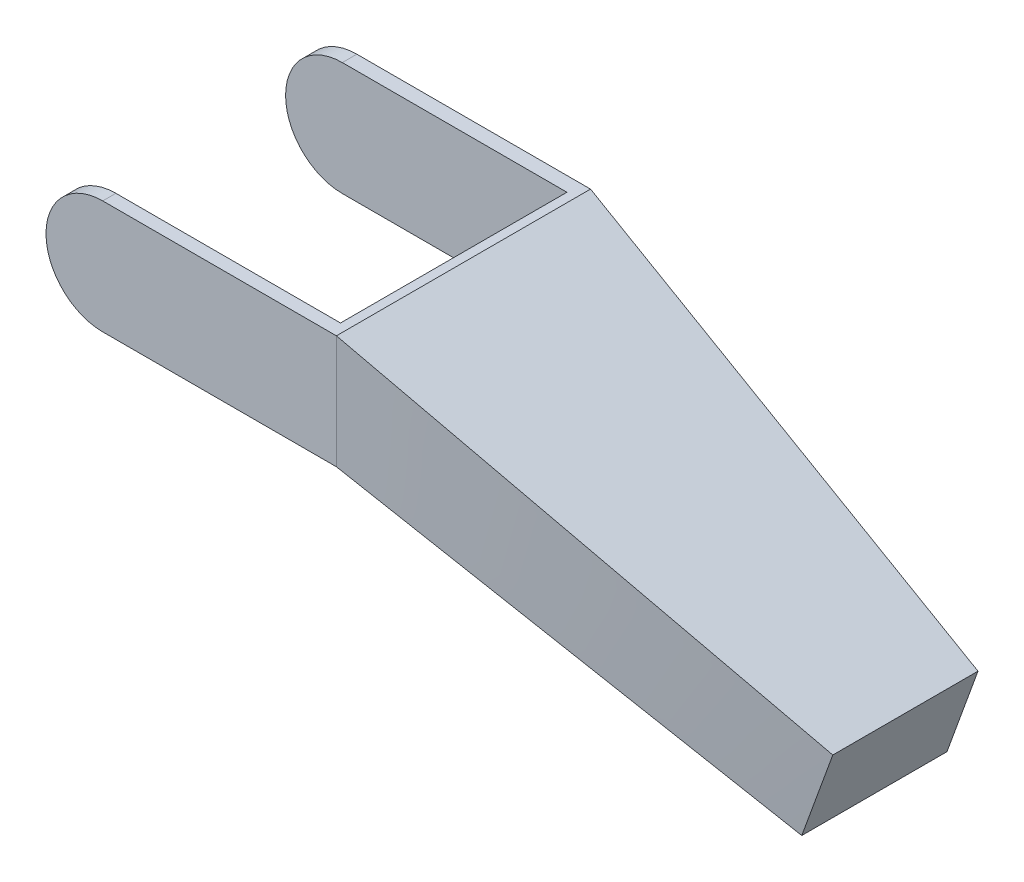
from build123d import *

# Parameters (mm, degrees)
EXTRUDE_1_DEPTH          = 28
CUT_EXTRUDE_1_DEPTH      = 25.1
CUT_EXTRUDE_1_DEPTH_BACK = 24.8
SKETCH_3_W               = 56
SKETCH_3_H               = 25
SKETCH_6_W               = 32
SKETCH_6_H               = 20


with BuildPart() as part:
    # Эскиз1 → Бобышка-Вытянуть1 (new body, symmetric)
    with BuildSketch(Plane.XY):
        with BuildLine():
            Line((0, 12.5), (51.5, 12.5))
            Line((51.5, 12.5), (51.5, -12.5))
            Line((51.5, -12.5), (0, -12.5))
            ThreePointArc((0, -12.5), (-12.5, 0), (0, 12.5))
        make_face()
    extrude(amount=EXTRUDE_1_DEPTH, both=True)

    # Эскиз2 → Вырез-Вытянуть1 (cut, two sides)
    with BuildSketch(Plane.XY) as cut_extrude_1_sk:
        with BuildLine():
            Line((0, 12.5), (49.5, 12.5))
            Line((49.5, 12.5), (49.5, -12.5))
            Line((49.5, -12.5), (0, -12.5))
            ThreePointArc((0, -12.5), (-12.5, 0), (0, 12.5))
        make_face()
    extrude(amount=CUT_EXTRUDE_1_DEPTH, mode=Mode.SUBTRACT)
    extrude(cut_extrude_1_sk.sketch, amount=-CUT_EXTRUDE_1_DEPTH_BACK, mode=Mode.SUBTRACT)

    # Эскиз3 → По сечениям1 section 0
    with BuildSketch(Plane(origin=(51.5, 0, 0), x_dir=(0, 0, -1), z_dir=(1, 0, 0))):
        Rectangle(SKETCH_3_W, SKETCH_3_H)
    # Эскиз6 → По сечениям1 section 1
    with BuildSketch(Plane(origin=(145.469262079, -34.202014333, 0), x_dir=(0, 0, -1), z_dir=(0.939692621, -0.342020143, 0))):
        Rectangle(SKETCH_6_W, SKETCH_6_H)
    loft()


solid = part.part
